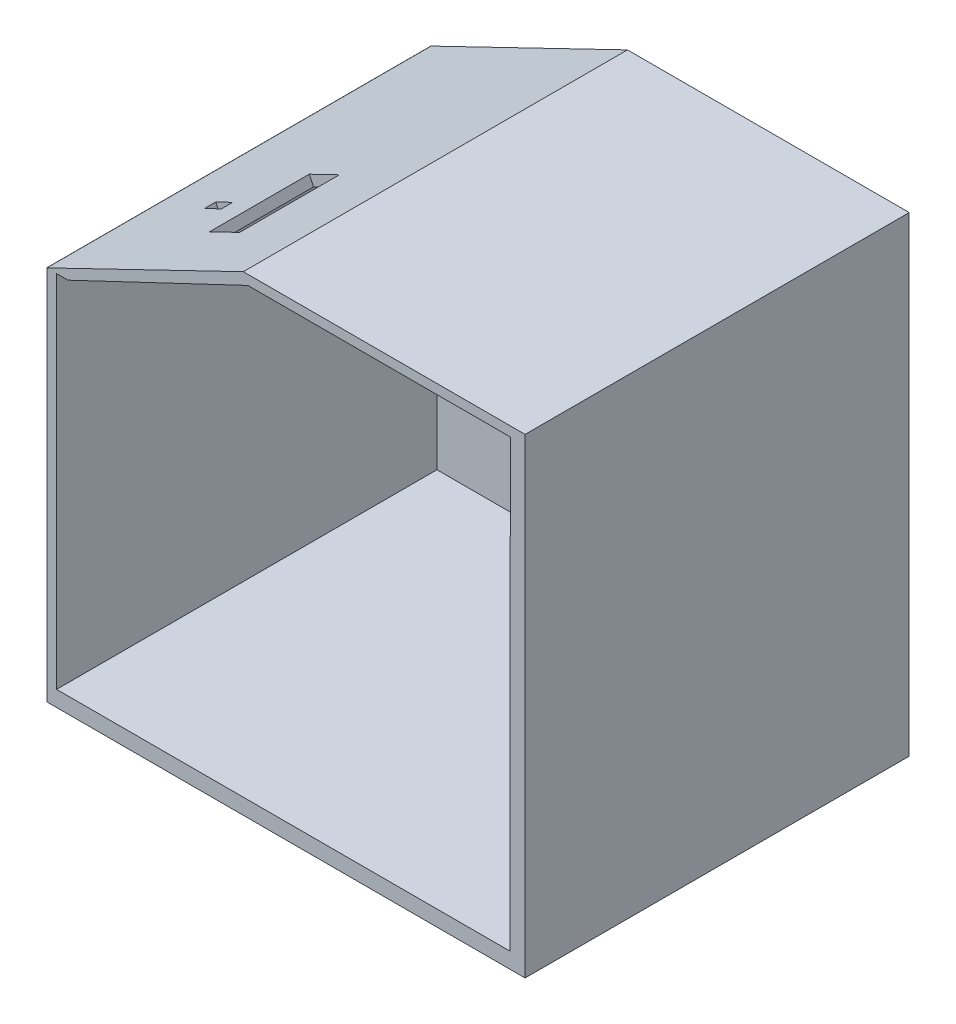
from build123d import *

# Parameters (mm, degrees)
SKETCH1_W           = 508
SKETCH1_H           = 408
SKETCH1_W_2         = 500
SKETCH1_H_2         = 400
BOSS_EXTRUDE1_DEPTH = 500
SKETCH1_3_W         = 500
SKETCH1_3_H         = 400
BOSS_EXTRUDE2_DEPTH = 500
SKETCH2_W           = 120
SKETCH2_H           = 180
CUT_EXTRUDE1_DEPTH  = 7.5
SKETCH4_W           = 481.787571452
SKETCH4_H           = 382.410311639
CUT_EXTRUDE3_DEPTH  = 404
CUT_EXTRUDE4_DEPTH  = 434
CUT_EXTRUDE5_DEPTH  = 404
SKETCH10_W          = 20
SKETCH10_H          = 12
SKETCH10_W_2        = 35.5
SKETCH10_H_2        = 106
CUT_EXTRUDE6_DEPTH  = 24


with BuildPart() as part:
    # Sketch1 → Boss-Extrude1 (new body)
    with BuildSketch(Plane(origin=(0, 0, 0), x_dir=(1, 0, 0), z_dir=(0, 1, 0))):
        with Locations((-0.117405467, -0.781547842)):
            Rectangle(SKETCH1_W, SKETCH1_H)
        with Locations((-0.117405467, -0.781547842)):
            Rectangle(SKETCH1_W_2, SKETCH1_H_2, mode=Mode.SUBTRACT)
    extrude(amount=BOSS_EXTRUDE1_DEPTH)

    # Sketch1_3 → Boss-Extrude2 (add)
    with BuildSketch(Plane(origin=(0, 0, 0), x_dir=(1, 0, 0), z_dir=(0, 1, 0))):
        with Locations((-0.117405467, -0.781547842)):
            Rectangle(SKETCH1_3_W, SKETCH1_3_H)
    extrude(amount=BOSS_EXTRUDE2_DEPTH)

    # Sketch2 → Cut-Extrude1 (cut, symmetric)
    with BuildSketch(Plane.ZY.offset(254.117405467)):
        with Locations((84.712563528, 234.953187265)):
            Rectangle(SKETCH2_W, SKETCH2_H)
    extrude(amount=CUT_EXTRUDE1_DEPTH, both=True, mode=Mode.SUBTRACT)

    # Sketch4 → Cut-Extrude3 (cut, symmetric)
    with BuildSketch(Plane.XY.offset(204.781547842)):
        with Locations((-2.789371367, 207.878900207)):
            Rectangle(SKETCH4_W, SKETCH4_H)
    extrude(amount=CUT_EXTRUDE3_DEPTH, both=True, mode=Mode.SUBTRACT)

    # Sketch8 → Cut-Extrude4 (cut, symmetric)
    with BuildSketch(Plane.XY.offset(204.781547842)):
        Polygon((-254.117405467, 399.203948512), (-253.994172888, 399.203948512), (-45.39037666, 500), (-254.117405467, 500), align=None)
    extrude(amount=CUT_EXTRUDE4_DEPTH, both=True, mode=Mode.SUBTRACT)

    # Sketch9 → Cut-Extrude5 (cut, symmetric)
    with BuildSketch(Plane.XY.offset(204.781547842)):
        Polygon((-40.587805706, 489.7694832), (-231.625791255, 399.084056026), (238.104414359, 399.084056026), (238.104414359, 398.17698413), (238.202409937, 398.17698413), (238.202409937, 489.7694832), align=None)
    extrude(amount=CUT_EXTRUDE5_DEPTH, both=True, mode=Mode.SUBTRACT)

    # Sketch10 → Cut-Extrude6 (cut, symmetric)
    with BuildSketch(Plane(origin=(-204.45830182, 423.139372032, 0), x_dir=(0.9003981876242824, 0.43506678076234173, 0), z_dir=(-0.43506678076234173, 0.9003981876242824, 0))):
        with Locations((17.482156961, -87.755377662)):
            Rectangle(SKETCH10_W, SKETCH10_H)
        with Locations((77.005207248, -82.022659024)):
            Rectangle(SKETCH10_W_2, SKETCH10_H_2)
    extrude(amount=CUT_EXTRUDE6_DEPTH, both=True, mode=Mode.SUBTRACT)


solid = part.part
